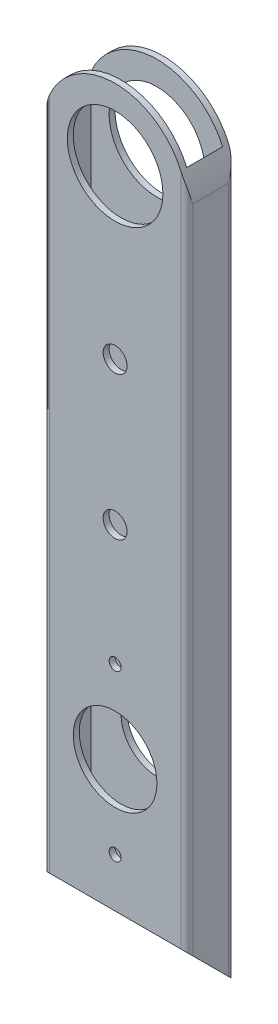
from build123d import *

# Parameters (mm, degrees)
SKETCH1_W           = 34.925
SKETCH1_H           = 9.525
BOSS_EXTRUDE1_DEPTH = 203.2
SKETCH2_R           = 3.175
SKETCH2_R_2         = 12.7
SKETCH2_R_3         = 1.5875
SKETCH2_R_4         = 9.525
CUT_EXTRUDE1_DEPTH  = 13.7
CUT_EXTRUDE2_DEPTH  = 39.1000001
SKETCH4_R           = 11.1125
CUT_EXTRUDE3_DEPTH  = 1.5875


with BuildPart() as part:
    # Sketch1 → Boss-Extrude1 (new body)
    with BuildSketch(Plane(origin=(0, 0, 0), x_dir=(1, 0, 0), z_dir=(0, 1, 0))):
        with BuildLine():
            Line((1.5875, 0), (36.5125, 0))
            ThreePointArc((36.5125, 0), (37.635032015, 0.464967985), (38.1, 1.5875))
            Line((38.1, 1.5875), (38.1, 11.1125))
            ThreePointArc((38.1, 11.1125), (37.635032015, 12.235032015), (36.5125, 12.7))
            Line((36.5125, 12.7), (1.5875, 12.7))
            ThreePointArc((1.5875, 12.7), (0.464967985, 12.235032015), (0, 11.1125))
            Line((0, 11.1125), (0, 1.5875))
            ThreePointArc((0, 1.5875), (0.464967985, 0.464967985), (1.5875, 0))
        make_face()
        with Locations((19.05, 6.35)):
            Rectangle(SKETCH1_W, SKETCH1_H, mode=Mode.SUBTRACT)
    extrude(amount=BOSS_EXTRUDE1_DEPTH)

    # Sketch2 → Cut-Extrude1 (cut, through all)
    with BuildSketch(Plane.XY):
        with Locations((19.05, 101.6)):
            Circle(SKETCH2_R)
        with Locations((19.05, 139.7)):
            Circle(SKETCH2_R)
        with Locations((19.05, 184.15)):
            Circle(SKETCH2_R_2)
        with Locations((19.05, 25.704689783)):
            Circle(SKETCH2_R_3)
        with Locations((19.05, 47.625)):
            Circle(SKETCH2_R_4)
        with Locations((19.05, 69.545310217)):
            Circle(SKETCH2_R_3)
        with BuildLine():
            Line((0, 184.15), (0, 209.55))
            Line((0, 209.55), (38.1, 209.55))
            Line((38.1, 209.55), (38.1, 184.15))
            ThreePointArc((38.1, 184.15), (19.05, 203.2), (0, 184.15))
        make_face()
    extrude(amount=-CUT_EXTRUDE1_DEPTH, mode=Mode.SUBTRACT)

    # Sketch3 → Cut-Extrude2 (cut, through all)
    with BuildSketch(Plane(origin=(38.1, 0, 0), x_dir=(0, 0, -1), z_dir=(1, 0, 0))):
        Polygon((0, 0), (12.7, 0), (0, 12.7), align=None)
    extrude(amount=-CUT_EXTRUDE2_DEPTH, mode=Mode.SUBTRACT)

    # Sketch4 → Cut-Extrude3 (cut)
    with BuildSketch(Plane.XY):
        with Locations((19.05, 47.625)):
            Circle(SKETCH4_R)
    extrude(amount=-CUT_EXTRUDE3_DEPTH, mode=Mode.SUBTRACT)


solid = part.part
